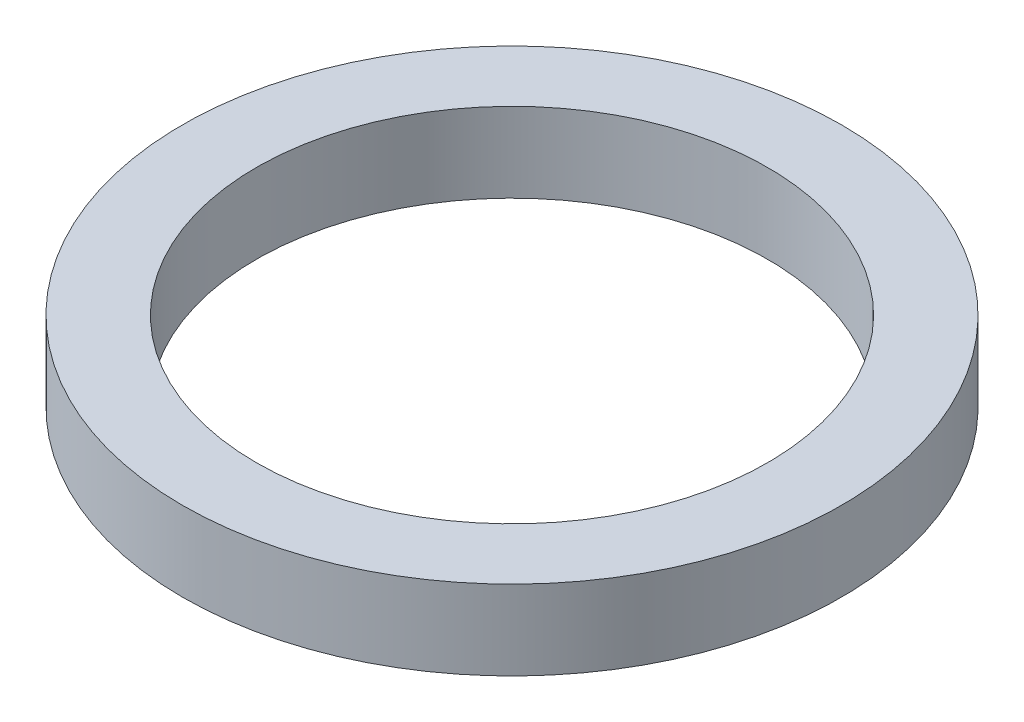
from build123d import *

# Parameters (mm, degrees)
SKETCH1_R           = 29
SKETCH1_R_2         = 22.5
BOSS_EXTRUDE1_DEPTH = 7


with BuildPart() as part:
    # Sketch1 → Boss-Extrude1 (new body)
    with BuildSketch(Plane(origin=(0, 0, 0), x_dir=(1, 0, 0), z_dir=(0, 1, 0))):
        Circle(SKETCH1_R)
        Circle(SKETCH1_R_2, mode=Mode.SUBTRACT)
    extrude(amount=BOSS_EXTRUDE1_DEPTH)


solid = part.part
